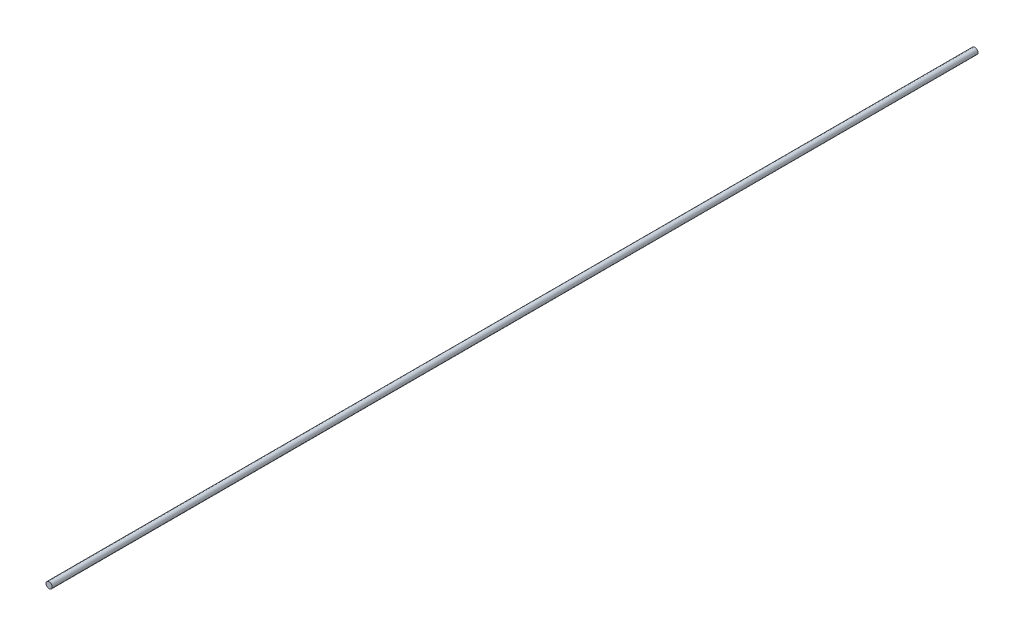
from build123d import *

# Parameters (mm, degrees)
SKETCH1_R           = 6
BOSS_EXTRUDE1_DEPTH = 900


with BuildPart() as part:
    # Sketch1 → Boss-Extrude1 (new body, symmetric)
    with BuildSketch(Plane.XY):
        Circle(SKETCH1_R)
    extrude(amount=BOSS_EXTRUDE1_DEPTH, both=True)


solid = part.part
